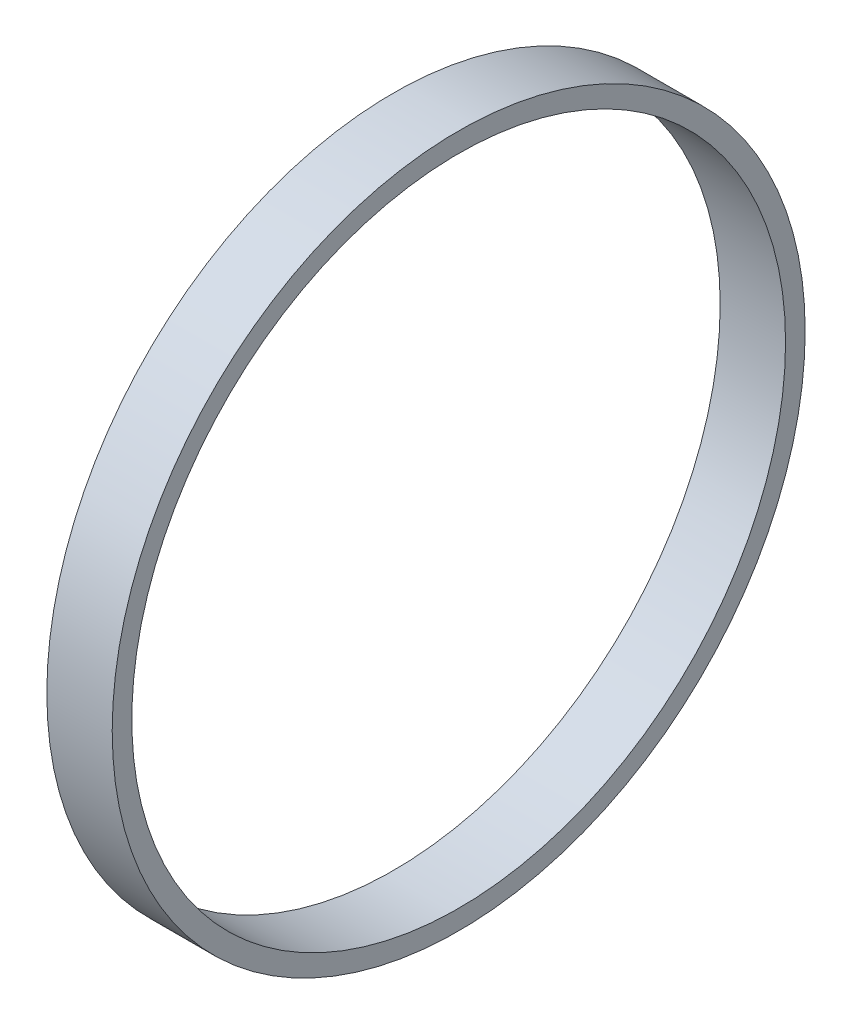
from build123d import *

# Parameters (mm, degrees)
SKETCH1_R           = 26.5
SKETCH1_R_2         = 25
BOSS_EXTRUDE1_DEPTH = 5


with BuildPart() as part:
    # Sketch1 → Boss-Extrude1 (new body)
    with BuildSketch(Plane(origin=(0, 0, 0), x_dir=(0, 0, -1), z_dir=(1, 0, 0))):
        Circle(SKETCH1_R)
        Circle(SKETCH1_R_2, mode=Mode.SUBTRACT)
    extrude(amount=BOSS_EXTRUDE1_DEPTH)


solid = part.part
